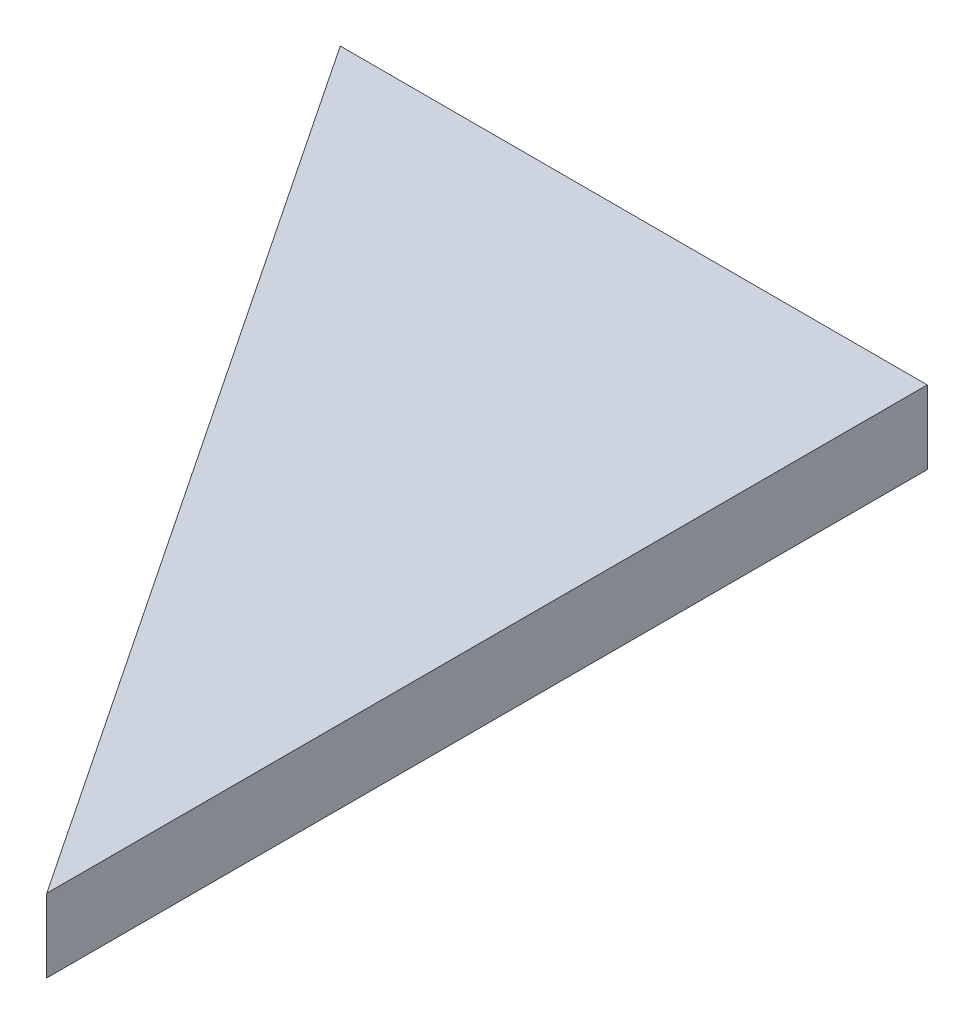
from build123d import *

# Parameters (mm, degrees)
BOSS_EXTRUDE1_DEPTH = 12.7


with BuildPart() as part:
    # Sketch1 → Boss-Extrude1 (new body)
    with BuildSketch(Plane(origin=(0, 0, 0), x_dir=(1, 0, 0), z_dir=(0, 1, 0))):
        Polygon((0, 0), (101.6, 0), (101.6, -152.4), align=None)
    extrude(amount=BOSS_EXTRUDE1_DEPTH)


solid = part.part
